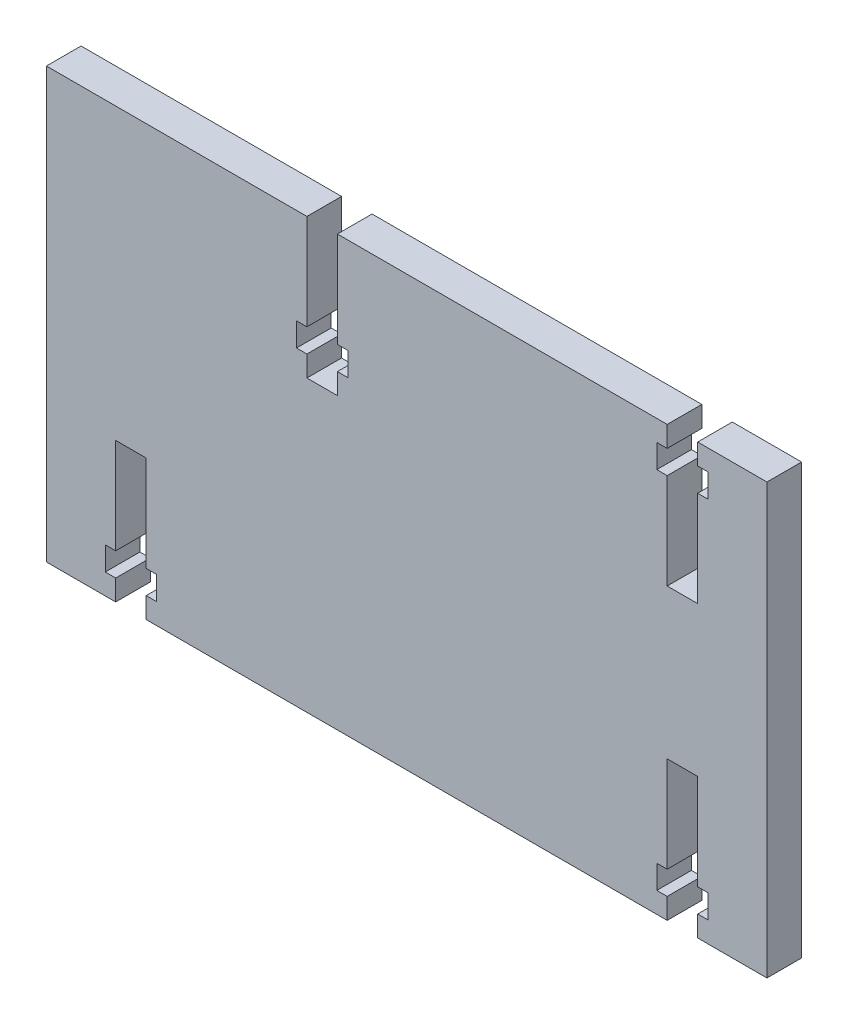
from build123d import *

# Parameters (mm, degrees)
SKETCH1_W           = 104
SKETCH1_H           = 62
BOSS_EXTRUDE1_DEPTH = 5
CUT_EXTRUDE1_DEPTH  = 10


with BuildPart() as part:
    # Sketch1 → Boss-Extrude1 (new body)
    with BuildSketch(Plane.XY):
        Rectangle(SKETCH1_W, SKETCH1_H)
    extrude(amount=BOSS_EXTRUDE1_DEPTH)

    # Sketch2 → Cut-Extrude1 (cut)
    with BuildSketch(Plane(origin=(0, 0, 0), x_dir=(-1, 0, 0), z_dir=(0, 0, -1))):
        Polygon((-37.6, -28), (-37.6, -31), (-42, -31), (-42, -28), (-43.5, -28), (-43.5, -24.6), (-42, -24.6), (-42, -10.8), (-37.6, -10.8), (-37.6, -24.6), (-36.1, -24.6), (-36.1, -28), align=None)
        Polygon((42, -31), (42, -28), (43.5, -28), (43.5, -24.6), (42, -24.6), (42, -10.8), (37.6, -10.8), (37.6, -24.6), (36.1, -24.6), (36.1, -28), (37.6, -28), (37.6, -31), align=None)
        Polygon((-42, 31), (-42, 28), (-43.5, 28), (-43.5, 24.6), (-42, 24.6), (-42, 10.8), (-37.6, 10.8), (-37.6, 24.6), (-36.1, 24.6), (-36.1, 28), (-37.6, 28), (-37.6, 31), align=None)
        Polygon((14.4, 13.8), (14.4, 10.8), (10, 10.8), (10, 13.8), (8.5, 13.8), (8.5, 17.2), (10, 17.2), (10, 31), (14.4, 31), (14.4, 17.2), (15.9, 17.2), (15.9, 13.8), align=None)
    extrude(amount=-CUT_EXTRUDE1_DEPTH, mode=Mode.SUBTRACT)


solid = part.part
